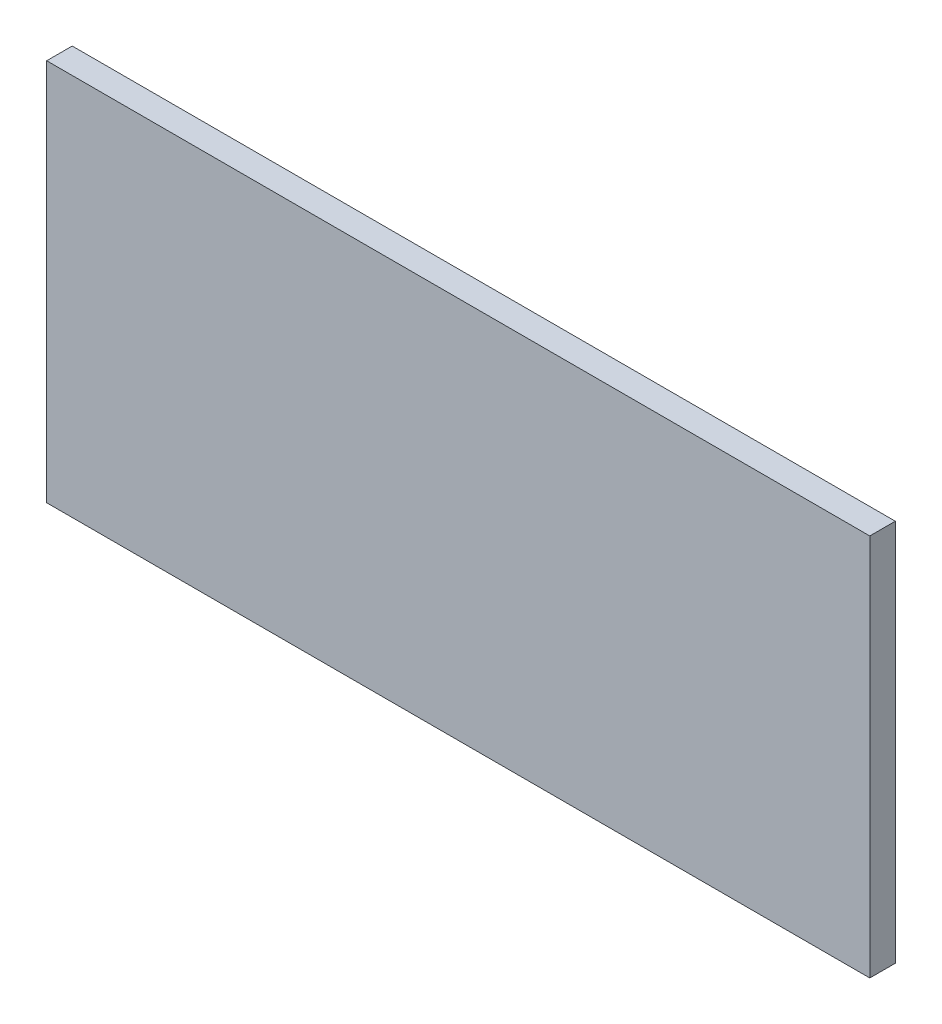
from build123d import *

# Parameters (mm, degrees)
CROQUIS1_W              = 645
CROQUIS1_H              = 300
SALIENTE_EXTRUIR1_DEPTH = 20


with BuildPart() as part:
    # Croquis1 → Saliente-Extruir1 (new body)
    with BuildSketch(Plane.XY):
        with Locations((-34.36988741, 89.706601467)):
            Rectangle(CROQUIS1_W, CROQUIS1_H)
    extrude(amount=SALIENTE_EXTRUIR1_DEPTH)


solid = part.part
